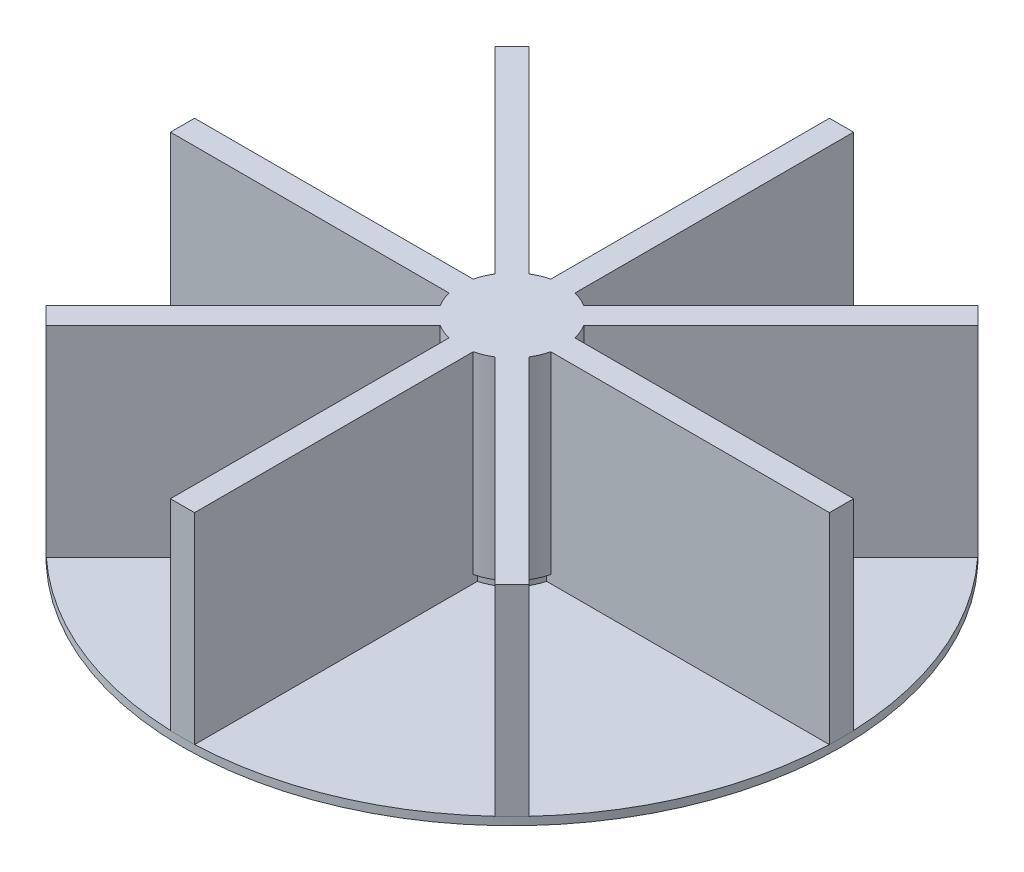
from build123d import *

# Parameters (mm, degrees)
SKETCH1_R            = 41
BOSS_EXTRUDE1_DEPTH  = 1
SKETCH6_W            = 3
SKETCH6_H            = 41
BOSS_EXTRUDE7_DEPTH  = 25
SKETCH7_R            = 6
BOSS_EXTRUDE8_DEPTH  = 24
SKETCH9_R            = 6
CUT_EXTRUDE3_DEPTH   = 5
CIRPATTERN1_COUNT    = 8
SKETCH11_R           = 6
CUT_EXTRUDE5_DEPTH   = 6
BOSS_EXTRUDE9_DEPTH  = 2
CIRPATTERN2_COUNT    = 8
FILLET1_R            = 1
SKETCH13_R           = 6.5
BOSS_EXTRUDE17_DEPTH = 6
SKETCH16_R           = 6.5
SKETCH16_R_2         = 6
BOSS_EXTRUDE18_DEPTH = 24
SKETCH15_R           = 6
BOSS_EXTRUDE19_DEPTH = 3
SKETCH17_R           = 3.075
CUT_EXTRUDE10_DEPTH  = 5


with BuildPart() as part:
    # Sketch1 → Boss-Extrude1 (new body)
    with BuildSketch(Plane(origin=(0, 0, 0), x_dir=(1, 0, 0), z_dir=(0, 1, 0))):
        Circle(SKETCH1_R)
    extrude(amount=BOSS_EXTRUDE1_DEPTH)

    # Sketch6 → Boss-Extrude7 (add)
    with BuildSketch(Plane(origin=(0, 1, 0), x_dir=(1, 0, 0), z_dir=(0, 1, 0))):
        with Locations((0, -20.5)):
            Rectangle(SKETCH6_W, SKETCH6_H)
    boss_extrude7 = extrude(amount=BOSS_EXTRUDE7_DEPTH)

    # Sketch7 → Boss-Extrude8 (add)
    with BuildSketch(Plane.XZ):
        Circle(SKETCH7_R)
    extrude(amount=-BOSS_EXTRUDE8_DEPTH)

    # Sketch9 → Cut-Extrude3 (cut)
    with BuildSketch(Plane(origin=(0, 26, 0), x_dir=(1, 0, 0), z_dir=(0, 1, 0))):
        Circle(SKETCH9_R)
    extrude(amount=-CUT_EXTRUDE3_DEPTH, mode=Mode.SUBTRACT)

    # CirPattern1: Boss-Extrude7 ×8 about axis
    cirpattern1_axis = Axis((0, 0, 0), (0, 1, 0))
    for i in range(1, CIRPATTERN1_COUNT):
        add(boss_extrude7.rotate(cirpattern1_axis, i * 360 / CIRPATTERN1_COUNT))

    # Sketch11 → Cut-Extrude5 (cut)
    with BuildSketch(Plane(origin=(0, 26, 0), x_dir=(1, 0, 0), z_dir=(0, 1, 0))):
        Circle(SKETCH11_R)
    extrude(amount=-CUT_EXTRUDE5_DEPTH, mode=Mode.SUBTRACT)

    # Sketch10 → Boss-Extrude9 (add)
    with BuildSketch(Plane(origin=(0, 0, 0), x_dir=(-1, 0, 0), z_dir=(0, -1, 0))):
        Polygon((-3.142992858, 11.677824964), (-5.920826915, 10.544847493), (-7.809122701, 15.174570921), (-5.031288644, 16.307548393), align=None)
    boss_extrude9 = extrude(amount=BOSS_EXTRUDE9_DEPTH)

    # CirPattern2: Boss-Extrude9 ×8 about axis
    cirpattern2_axis = Axis((0, 0, 0), (0, 1, 0))
    for i in range(1, CIRPATTERN2_COUNT):
        add(boss_extrude9.rotate(cirpattern2_axis, i * 360 / CIRPATTERN2_COUNT))

    # Fillet1
    fillet1_edges = [part.edges().sort_by_distance(p)[0] for p in [
        (4.087140751, -2, -13.992686678),
        (6.420205673, -2, -15.741059657),
        (6.864974808, -2, -12.859709207),
        (4.531909887, -2, -11.111336228),
        (-7.004278697, -2, -12.784368578),
        (-6.590839059, -2, -15.670380994),
        (-4.238917345, -2, -13.947457824),
        (-4.652356983, -2, -11.061445408),
        (-13.992686678, -2, -4.087140751),
        (-15.741059657, -2, -6.420205673),
        (-12.859709207, -2, -6.864974808),
        (-11.111336228, -2, -4.531909887),
        (-12.784368578, -2, 7.004278697),
        (-15.670380994, -2, 6.590839059),
        (-13.947457824, -2, 4.238917345),
        (-11.061445408, -2, 4.652356983),
        (-4.087140751, -2, 13.992686678),
        (-6.420205673, -2, 15.741059657),
        (-6.864974808, -2, 12.859709207),
        (-4.531909887, -2, 11.111336228),
        (7.004278697, -2, 12.784368578),
        (6.590839059, -2, 15.670380994),
        (4.238917345, -2, 13.947457824),
        (4.652356983, -2, 11.061445408),
        (13.992686678, -2, 4.087140751),
        (15.741059657, -2, 6.420205673),
        (12.859709207, -2, 6.864974808),
        (11.111336228, -2, 4.531909887),
        (12.784368578, -2, -7.004278697),
        (15.670380994, -2, -6.590839059),
        (13.947457824, -2, -4.238917345),
        (11.061445408, -2, -4.652356983),
    ]]
    fillet(fillet1_edges, radius=FILLET1_R)

    # Sketch13 → Boss-Extrude17 (add)
    with BuildSketch(Plane(origin=(0, 20, 0), x_dir=(1, 0, 0), z_dir=(0, 1, 0))):
        Circle(SKETCH13_R)
    extrude(amount=BOSS_EXTRUDE17_DEPTH)

    # Sketch16 → Boss-Extrude18 (add)
    with BuildSketch(Plane(origin=(0, 26, 0), x_dir=(1, 0, 0), z_dir=(0, 1, 0))):
        Circle(SKETCH16_R)
        Circle(SKETCH16_R_2, mode=Mode.SUBTRACT)
    extrude(amount=-BOSS_EXTRUDE18_DEPTH)

    # Sketch15 → Boss-Extrude19 (add)
    with BuildSketch(Plane.XZ):
        Circle(SKETCH15_R)
    extrude(amount=BOSS_EXTRUDE19_DEPTH)

    # Sketch17 → Cut-Extrude10 (cut)
    with BuildSketch(Plane.XZ.offset(3)):
        Circle(SKETCH17_R)
    extrude(amount=-CUT_EXTRUDE10_DEPTH, mode=Mode.SUBTRACT)


solid = part.part
